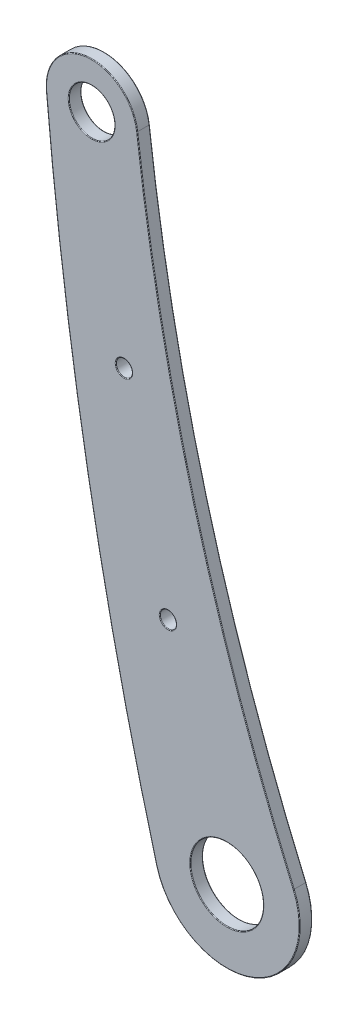
from build123d import *

# Parameters (mm, degrees)
SZKIC2_R                    = 5.5
SZKIC2_R_2                  = 8.75
DODANIE_WYCI_GNI_CIE1_DEPTH = 3
OTW_R_POD_RUB_M3_51_D       = 3.9
ZAOKR_GLENIE1_R             = 0.15


with BuildPart() as part:
    # Szkic2 → Dodanie-wyciągnięcie1 (new body)
    with BuildSketch(Plane.XY):
        with BuildLine():
            ThreePointArc((-41.746498305, 203.298923565), (-27.96744414, 132.559559254), (-4.161828095, 64.535940992))
            ThreePointArc((-4.161828095, 64.535940992), (-14.428399098, 41.066146453), (-37.105235885, 52.982303936))
            ThreePointArc((-37.105235885, 52.982303936), (-53.64442572, 126.406057299), (-63.623827723, 201.005011005))
            ThreePointArc((-63.623827723, 201.005011005), (-53.814168096, 212.919429187), (-41.746498305, 203.298923565))
        make_face()
        with Locations((-52.667069104, 201.979403415)):
            Circle(SZKIC2_R, mode=Mode.SUBTRACT)
        with Locations((-20.22, 57.58)):
            Circle(SZKIC2_R_2, mode=Mode.SUBTRACT)
    extrude(amount=DODANIE_WYCI_GNI_CIE1_DEPTH)

    # Otwór pod śrubę M3.51 (through all)
    with Locations(Plane.XY.offset(3)):
        with Locations((-44.921172735, 152.583036246), (-34.350804004, 105.54165529)):
            Hole(OTW_R_POD_RUB_M3_51_D / 2)

    # Zaokrąglenie1
    zaokr_glenie1_edges = [part.edges().sort_by_distance(p)[0] for p in [
        (-14.428399098, 41.066146453, 3),
        (-58.167069104, 201.979403415, 0),
        (-58.167069104, 201.979403415, 3),
        (-27.96744414, 132.559559254, 3),
        (-28.97, 57.58, 0),
        (-28.97, 57.58, 3),
        (-32.400804004, 105.54165529, 3),
        (-32.400804004, 105.54165529, 0),
        (-42.971172735, 152.583036246, 3),
        (-42.971172735, 152.583036246, 0),
        (-53.814168096, 212.919429187, 3),
        (-27.96744414, 132.559559254, 0),
        (-14.428399098, 41.066146453, 0),
        (-53.64442572, 126.406057299, 0),
        (-53.814168096, 212.919429187, 0),
        (-53.64442572, 126.406057299, 3),
    ]]
    fillet(zaokr_glenie1_edges, radius=ZAOKR_GLENIE1_R)


solid = part.part
